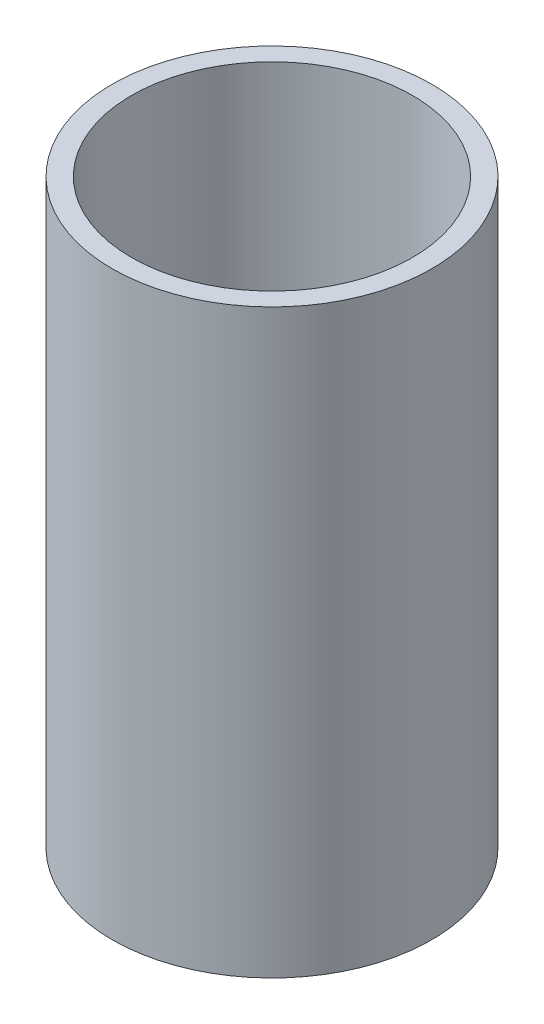
from build123d import *

# Parameters (mm, degrees)
SKETCH1_R           = 33
SKETCH1_R_2         = 29
BOSS_EXTRUDE1_DEPTH = 120


with BuildPart() as part:
    # Sketch1 → Boss-Extrude1 (new body)
    with BuildSketch(Plane(origin=(0, 0, 0), x_dir=(1, 0, 0), z_dir=(0, 1, 0))):
        Circle(SKETCH1_R)
        Circle(SKETCH1_R_2, mode=Mode.SUBTRACT)
    extrude(amount=BOSS_EXTRUDE1_DEPTH)


solid = part.part
